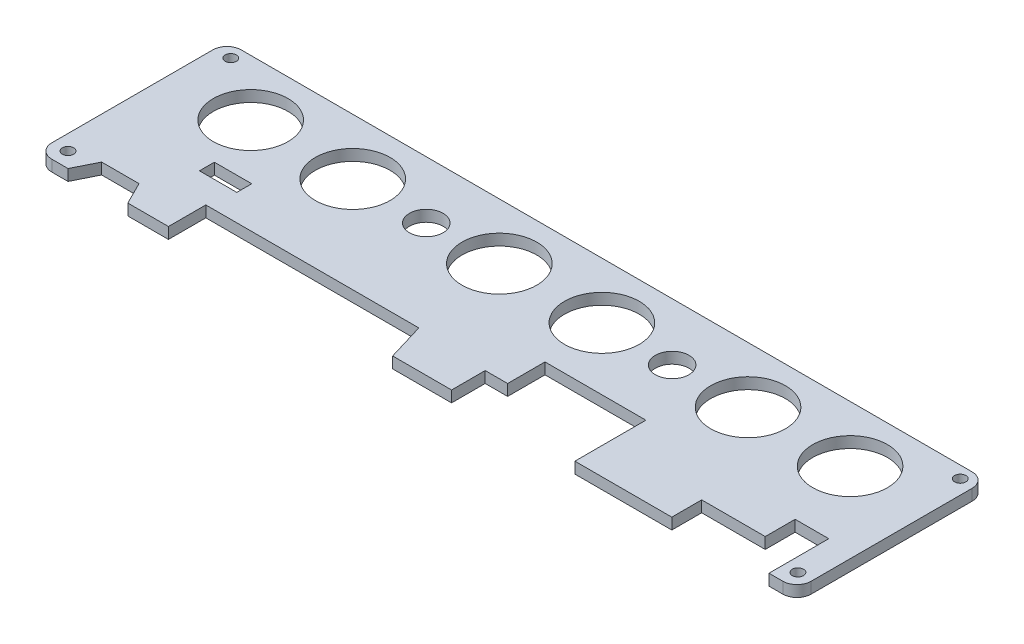
from build123d import *

# Parameters (mm, degrees)
SKETCH_1_R      = 1.5
SKETCH_1_W      = 10
SKETCH_1_H      = 4
SKETCH_1_R_2    = 10
SKETCH_1_R_3    = 4.5
EXTRUDE_1_DEPTH = 3
FILLET_1_R      = 3.8


with BuildPart() as part:
    # 草图1 → 凸台-拉伸1 (new body)
    with BuildSketch(Plane(origin=(0, 0, 0), x_dir=(1, 0, 0), z_dir=(0, 1, 0))):
        Polygon((195.7, 16), (195.7, 0), (203.2, 0), (203.2, 50.673), (0, 50.673), (0, 0), (8.129, 0), (11.129, 6), (21.129, 6), (24.129, 0), (35, 0), (35, 10), (61.620357325, 10), (79.620357325, 10), (81, 10), (92, 10), (95, 0), (110.764, 0), (110.764, 9), (116.764, 9), (116.764, 19), (143.764, 19), (143.764, 0), (169.7, 0), (169.7, 8), (186.7, 8), (186.7, 16), align=None)
        with Locations((4.064, 4.064)):
            Circle(SKETCH_1_R, mode=Mode.SUBTRACT)
        with Locations((31.242, 19.05)):
            Rectangle(SKETCH_1_W, SKETCH_1_H, mode=Mode.SUBTRACT)
        with Locations((199.39, 4.064)):
            Circle(SKETCH_1_R, mode=Mode.SUBTRACT)
        with Locations((21.336, 35.673)):
            Circle(SKETCH_1_R_2, mode=Mode.SUBTRACT)
        with Locations((48.641, 35.673)):
            Circle(SKETCH_1_R_2, mode=Mode.SUBTRACT)
        with Locations((68.691, 35.306)):
            Circle(SKETCH_1_R_3, mode=Mode.SUBTRACT)
        with Locations((87.884, 35.673)):
            Circle(SKETCH_1_R_2, mode=Mode.SUBTRACT)
        with Locations((4.318, 47.371)):
            Circle(SKETCH_1_R, mode=Mode.SUBTRACT)
        with Locations((115.316, 35.673)):
            Circle(SKETCH_1_R_2, mode=Mode.SUBTRACT)
        with Locations((134.493, 35.306)):
            Circle(SKETCH_1_R_3, mode=Mode.SUBTRACT)
        with Locations((154.432, 35.673)):
            Circle(SKETCH_1_R_2, mode=Mode.SUBTRACT)
        with Locations((181.737, 35.673)):
            Circle(SKETCH_1_R_2, mode=Mode.SUBTRACT)
        with Locations((199.39, 47.498)):
            Circle(SKETCH_1_R, mode=Mode.SUBTRACT)
    extrude(amount=EXTRUDE_1_DEPTH)

    # 圆角1
    fillet_1_edges = [part.edges().sort_by_distance(p)[0] for p in [
        (0, 1.5, 0),
        (0, 1.5, -50.673),
        (203.2, 1.5, -50.673),
        (203.2, 1.5, 0),
    ]]
    fillet(fillet_1_edges, radius=FILLET_1_R)


solid = part.part
